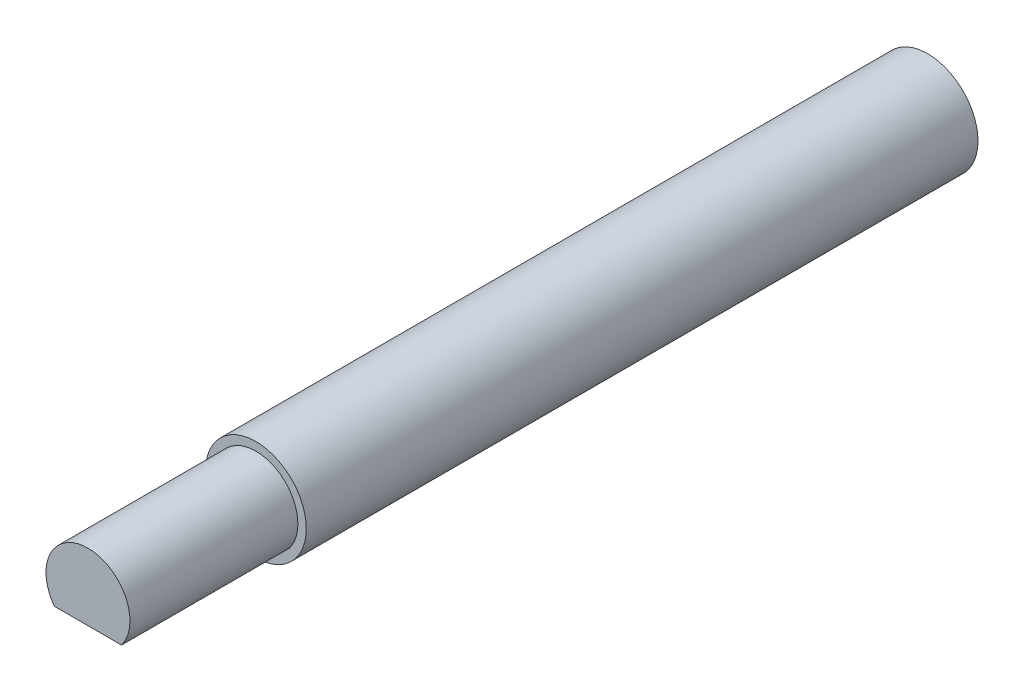
from build123d import *

# Parameters (mm, degrees)
SKETCH1_R           = 6
BOSS_EXTRUDE1_DEPTH = 80
BOSS_EXTRUDE2_DEPTH = 20


with BuildPart() as part:
    # Sketch1 → Boss-Extrude1 (new body)
    with BuildSketch(Plane.XY):
        Circle(SKETCH1_R)
    extrude(amount=BOSS_EXTRUDE1_DEPTH)

    # Sketch2 → Boss-Extrude2 (add)
    with BuildSketch(Plane.XY.offset(80)):
        with BuildLine():
            Line((-4, -3), (1.600927796, -3))
            Line((1.600927796, -3), (4, -3))
            ThreePointArc((4, -3), (0, 5), (-4, -3))
        make_face()
    extrude(amount=BOSS_EXTRUDE2_DEPTH)


solid = part.part
